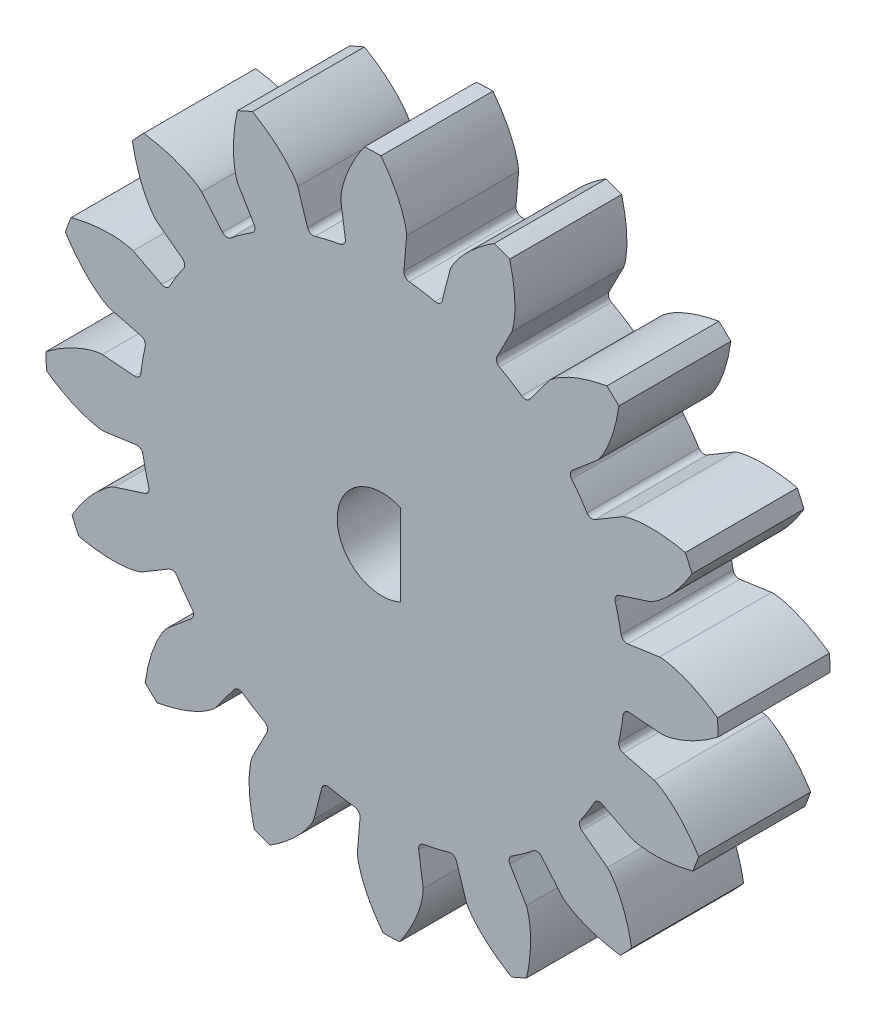
from build123d import *

# Parameters (mm, degrees)
SKETCH1_R           = 28.575
BOSS_EXTRUDE1_DEPTH = 9.525
CUT_EXTRUDE3_START  = -1
CUT_EXTRUDE3_DEPTH  = 11.525
CIRPATTERN1_COUNT   = 16
CUT_EXTRUDE4_DEPTH  = 10.5250001


with BuildPart() as part:
    # Sketch1 → Boss-Extrude1 (new body)
    with BuildSketch(Plane.XY):
        Circle(SKETCH1_R)
    extrude(amount=BOSS_EXTRUDE1_DEPTH)

    # Sketch2 → Cut-Extrude3 (cut)
    with BuildSketch(Plane.XY.offset(CUT_EXTRUDE3_START)):
        with BuildLine():
            add(Edge.make_bspline(
                [(23.77620788, -2.093455355), (23.784855177, -2.093498995), (23.809109822, -2.093224796), (23.854959368, -2.091140215), (23.929709022, -2.085515284), (24.024811371, -2.075082943), (24.147486608, -2.057855122), (24.291603862, -2.032754116), (24.449468197, -2.000145424), (24.620555517, -1.959264254), (24.790573225, -1.913713784), (24.959477444, -1.863855444), (25.127054845, -1.810211907), (25.329162308, -1.740554046), (25.570229411, -1.650534745), (25.849921792, -1.535920815), (26.164519201, -1.394889021), (26.482054511, -1.239456202), (26.791871273, -1.076929205), (27.101584701, -0.901824783), (27.398879602, -0.724688688), (27.703944629, -0.529701976), (27.983660117, -0.344109664), (28.258426435, -0.148503166), (28.422765424, -0.029097116), (28.534039358, 0.054709818), (28.574871256, 0.085776984)],
                knots=[0, 0, 0, 0, 0, 0.005376749, 0.015083688, 0.02853182, 0.04661014, 0.064854849, 0.092110525, 0.119476176, 0.146842496, 0.174208854, 0.201574956, 0.228941013, 0.256307345, 0.307035032, 0.361767352, 0.416499661, 0.471231937, 0.525964282, 0.580696616, 0.635428982, 0.690161387, 0.744893688, 0.799626082, 0.830142179, 0.830142179, 0.830142179, 0.830142179, 0.830142179], degree=4))
            Line((23.77620788, -2.093455355), (21.054233989, -1.866270196))
            ThreePointArc((21.054233989, -1.866270196), (20.689583457, -1.979924328), (20.507189153, -2.315512752))
            ThreePointArc((20.507189153, -2.315512752), (20.3519618, -3.421119285), (20.13717222, -4.516713541))
            ThreePointArc((20.13717222, -4.516713541), (20.199819102, -4.89349284), (20.507268199, -5.120125417))
            Line((20.507268199, -5.120125417), (23.153920222, -5.795394274))
            add(Edge.make_bspline(
                [(23.153920222, -5.795394274), (23.162049597, -5.79834231), (23.184714443, -5.806983361), (23.227017343, -5.824787603), (23.295215249, -5.855903454), (23.380849631, -5.898565418), (23.490008453, -5.957134719), (23.616566228, -6.030503467), (23.75342866, -6.115668893), (23.899839603, -6.213167492), (24.043632895, -6.314677864), (24.184892292, -6.419845693), (24.323598279, -6.528106782), (24.489170506, -6.663330604), (24.684262912, -6.831127432), (24.90709852, -7.035353955), (25.15355618, -7.276435101), (25.397792858, -7.532045115), (25.632334605, -7.791644074), (25.862431932, -8.063009484), (26.080173932, -8.331988807), (26.299036954, -8.620404247), (26.497360172, -8.891242135), (26.695576148, -9.181477704), (26.813643427, -9.358261475), (26.897896919, -9.489878822), (26.933350533, -9.545954853)],
                knots=[0, 0, 0, 0, 0, 0.005376749, 0.015083688, 0.02853182, 0.04661014, 0.064854849, 0.092110525, 0.119476176, 0.146842496, 0.174208854, 0.201574956, 0.228941013, 0.256307345, 0.307035032, 0.361767352, 0.416499661, 0.471231937, 0.525964282, 0.580696616, 0.635428982, 0.690161387, 0.744893688, 0.799626082, 0.838329536, 0.838329536, 0.838329536, 0.838329536, 0.838329536], degree=4))
            ThreePointArc((26.933350533, -9.545954853), (28.161597225, -4.84304313), (28.575, 0))
            ThreePointArc((28.575, 0), (28.574967814, 0.04288854), (28.574871256, 0.085776984))
        make_face()
    cut_extrude3 = extrude(amount=CUT_EXTRUDE3_DEPTH, mode=Mode.SUBTRACT)

    # CirPattern1: Cut-Extrude3 ×16 about axis
    cirpattern1_axis = Axis((0, 0, 9.525), (0, 0, 1))
    for i in range(1, CIRPATTERN1_COUNT):
        add(cut_extrude3.rotate(cirpattern1_axis, i * 360 / CIRPATTERN1_COUNT), mode=Mode.SUBTRACT)

    # Sketch3 → Cut-Extrude4 (cut, through all)
    with BuildSketch(Plane.XY.offset(9.525)):
        with BuildLine():
            Line((1.5875, 3.463516096), (1.5875, -3.463516096))
            ThreePointArc((1.5875, -3.463516096), (-3.81, 0), (1.5875, 3.463516096))
        make_face()
    extrude(amount=-CUT_EXTRUDE4_DEPTH, mode=Mode.SUBTRACT)


solid = part.part
